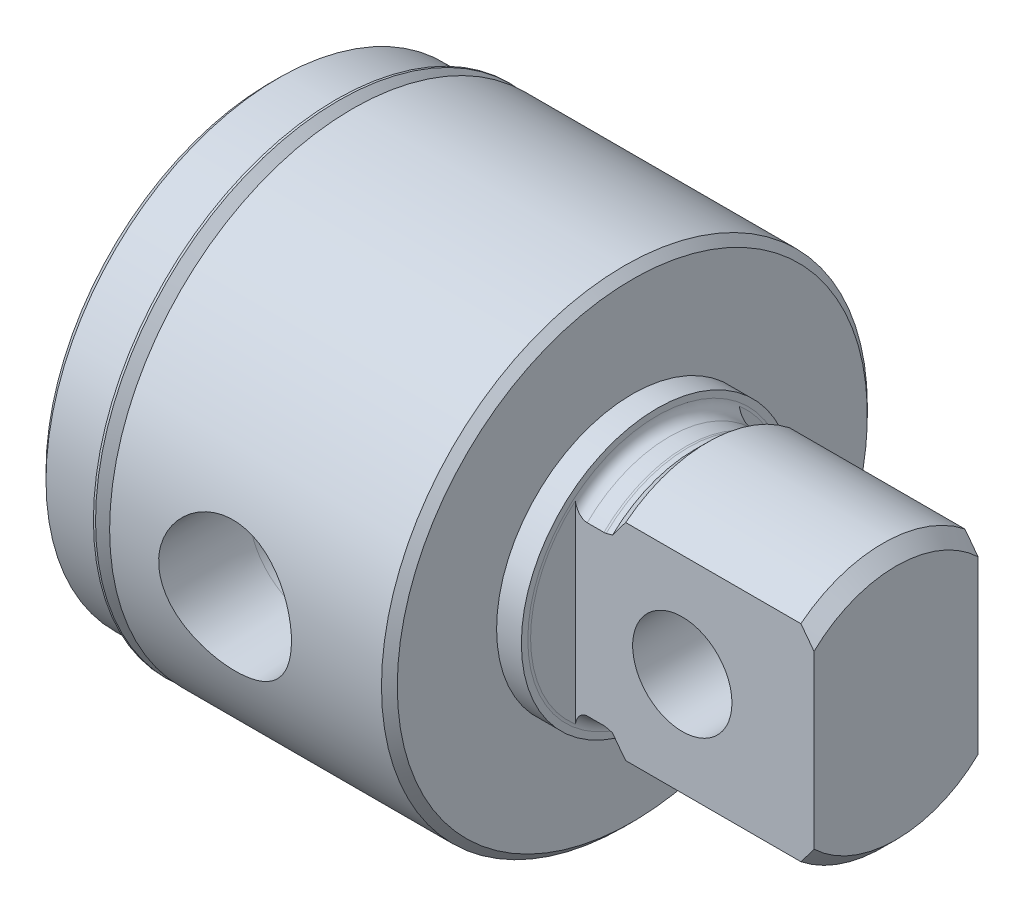
from build123d import *

# Parameters (mm, degrees)
SKETCH3_W               = 93.7006
SKETCH3_H               = 187.4012
SKETCH3_W_2             = 15.8115
SKETCH3_H_2             = 93.7006
CUT_EXTRUDE1_DEPTH      = 23.0124
HOLE1_D                 = 20.6248
HOLE1_DEPTH             = 27.94
HOLE1_TIP               = 5.953866916
SKETCH7_W               = 10.3124
SKETCH7_H               = 12.7
CUT_EXTRUDE2_DEPTH      = 11.858625
CUT_EXTRUDE2_DEPTH_BACK = 11.858625
SKETCH9_R               = 4.7879


with BuildPart() as part:
    # Sketch1 → Revolve1 (revolve)
    with BuildSketch(Plane.XY):
        Polygon((0, 0), (0, 21.63445), (0.762, 22.39645), (5.8166, 22.39645), (6.8707, 21.34235), (7.9248, 21.34235), (7.9248, 23.42515), (34.1376, 23.42515), (34.8996, 22.66315), (34.8996, 0), align=None)
    revolve(axis=Axis((34.8996, 0, 0), (-1, 0, 0)))

    # Sketch2 → Revolve2 (revolve)
    with BuildSketch(Plane.XY):
        with BuildLine():
            Line((34.8996, 0), (34.8996, 13.08735))
            Line((34.8996, 13.08735), (37.2872, 13.08735))
            Line((37.2872, 13.08735), (37.2872, 12.46505))
            ThreePointArc((37.2872, 12.46505), (37.629416437, 11.638866437), (38.4556, 11.29665))
            Line((38.4556, 11.29665), (40.0685, 11.29665))
            ThreePointArc((40.0685, 11.29665), (40.176691084, 11.301669903), (40.283952505, 11.316686478))
            Line((40.283952505, 11.316686478), (40.894683563, 11.43127))
            Line((40.894683563, 11.43127), (42.163413563, 12.7))
            Line((42.163413563, 12.7), (59.05627, 12.7))
            Line((59.05627, 12.7), (60.325, 11.43127))
            Line((60.325, 11.43127), (60.325, 0))
            Line((60.325, 0), (34.8996, 0))
        make_face()
    revolve(axis=Axis((60.325, 0, 0), (-1, 0, 0)))

    # Sketch3 → Cut-Extrude1 (cut)
    with BuildSketch(Plane(origin=(60.325, 0, 0), x_dir=(0, 0, -1), z_dir=(1, 0, 0))):
        Rectangle(SKETCH3_W, SKETCH3_H)
        Rectangle(SKETCH3_W_2, SKETCH3_H_2, mode=Mode.SUBTRACT)
    extrude(amount=-CUT_EXTRUDE1_DEPTH, mode=Mode.SUBTRACT)

    # Hole1
    with Locations(Plane.ZY):
        with Locations((0, 0)):
            Hole(HOLE1_D / 2, depth=HOLE1_DEPTH)
            with Locations((0, 0, -(HOLE1_DEPTH + HOLE1_TIP / 2))):  # 120° drill point
                Cone(0, HOLE1_D / 2, HOLE1_TIP, mode=Mode.SUBTRACT)

    # Sketch6 → Cut-Revolve1 (revolve, cut)
    with BuildSketch(Plane(origin=(0, 0, 0), x_dir=(1, 0, 0), z_dir=(0, 0.9998476951563913, 0.01745240643728403))):
        Polygon((19.05, 0), (25.187961617, 0), (25.187961617, -14.96695), (25.452022746, -23.42515), (19.05, -23.42515), align=None)
    revolve(axis=Axis((19.05, -0.408825239, 23.421582236), (0, 0.01745240643728403, -0.9998476951563913)), mode=Mode.SUBTRACT)

    # Sketch7 → Cut-Revolve2 (revolve, cut)
    with BuildSketch(Plane.XY):
        with Locations((5.1562, 6.35)):
            Rectangle(SKETCH7_W, SKETCH7_H)
    revolve(axis=Axis((10.3124, 0, 0), (-1, 0, 0)), mode=Mode.SUBTRACT)

    # Sketch8 → Revolve3 (revolve)
    with BuildSketch(Plane.XY):
        with BuildLine():
            Line((6.362790712, 23.340981804), (7.789783697, 21.913988819))
            ThreePointArc((7.789783697, 21.913988819), (7.826981136, 21.824186258), (7.789783697, 21.734383697))
            Line((7.789783697, 21.734383697), (7.39775, 21.34235))
            Line((7.39775, 21.34235), (6.8707, 21.34235))
            Line((6.8707, 21.34235), (6.8707, 21.08835))
            Line((6.8707, 21.08835), (7.9248, 21.08835))
            Line((7.9248, 21.08835), (7.9248, 22.066340712))
            Line((7.9248, 22.066340712), (6.565990712, 23.42515))
            Line((6.565990712, 23.42515), (6.362790712, 23.42515))
            Line((6.362790712, 23.42515), (6.362790712, 23.340981804))
        make_face()
    revolve(axis=Axis((7.9248, 0, 0), (-1, 0, 0)))

    # Sketch9 → Cut-Extrude2 (cut, two sides: drawn at the far end of the back side and taken through both)
    with BuildSketch(Plane.XY.offset(-CUT_EXTRUDE2_DEPTH_BACK)):
        with Locations((47.625, 0)):
            Circle(SKETCH9_R)
    extrude(amount=CUT_EXTRUDE2_DEPTH + CUT_EXTRUDE2_DEPTH_BACK, mode=Mode.SUBTRACT)


solid = part.part
